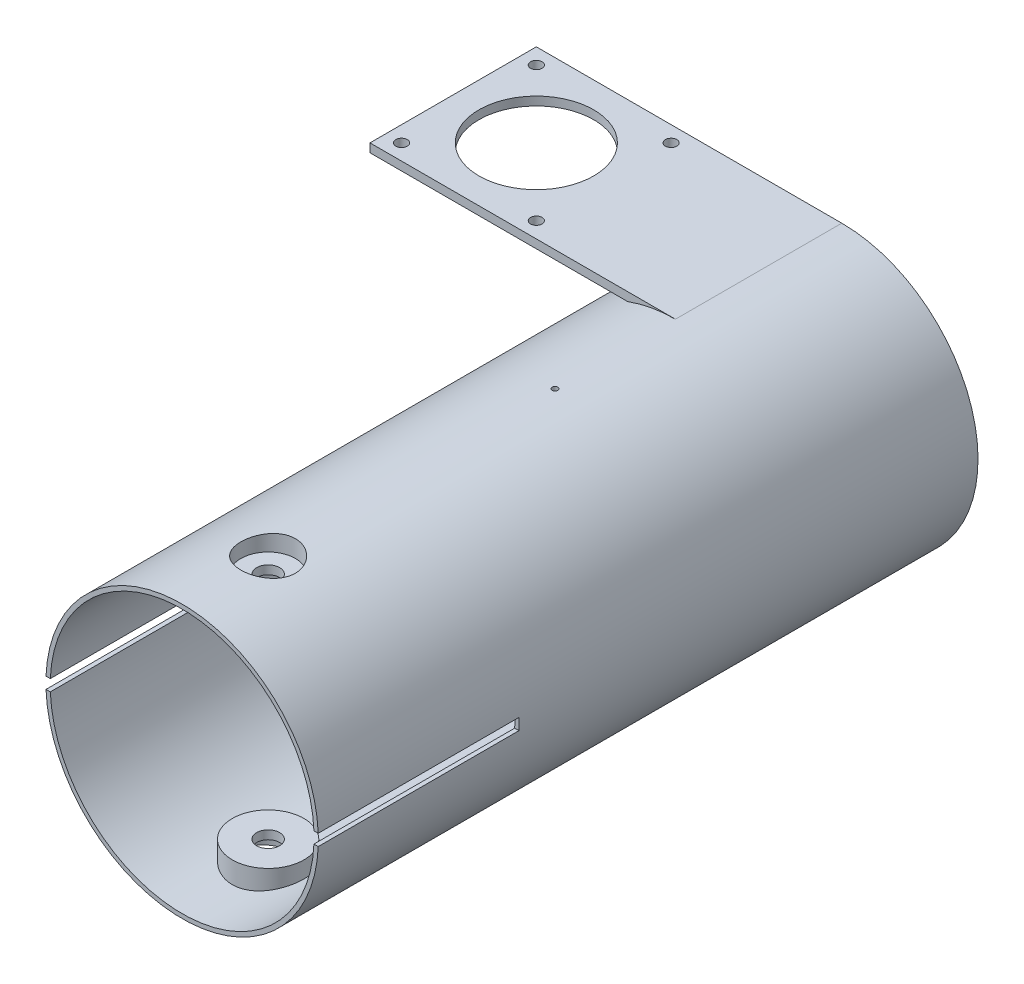
from build123d import *

# Parameters (mm, degrees)
SKETCH1_R               = 47.5
SKETCH1_R_2             = 46
BOSS_EXTRUDE1_DEPTH     = 250
CUT_EXTRUDE1_DEPTH      = 250
CUT_EXTRUDE1_DEPTH_BACK = 250
SKETCH2_R               = 1
CUT_EXTRUDE2_DEPTH      = 75
CUT_EXTRUDE2_DEPTH_BACK = 79
SKETCH3_W               = 95
SKETCH3_H               = 20
CUT_EXTRUDE3_DEPTH      = 64
CUT_EXTRUDE3_DEPTH_BACK = 73
SKETCH4_R               = 9.5
BOSS_EXTRUDE2_REACH     = 271.587
SKETCH5_R               = 12.5
SKETCH5_R_2             = 9.5
BOSS_EXTRUDE7_START     = 3
SKETCH10_R              = 12.5
SKETCH10_R_2            = 4
BOSS_EXTRUDE7_DEPTH     = 3
BOSS_EXTRUDE8_REACH     = 271.587
SKETCH12_R              = 12.5
SKETCH12_R_2            = 9.5
SKETCH13_R              = 12.5
SKETCH13_R_2            = 4
BOSS_EXTRUDE9_DEPTH     = 3
BOSS_EXTRUDE11_DEPTH    = 58
SKETCH18_R              = 2
SKETCH18_R_2            = 20
CUT_EXTRUDE5_DEPTH      = 58
CUT_EXTRUDE6_DEPTH      = 98
CUT_EXTRUDE6_DEPTH_BACK = 82


with BuildPart() as part:
    # Sketch1 → Boss-Extrude1 (new body)
    with BuildSketch(Plane.XY):
        Circle(SKETCH1_R)
        Circle(SKETCH1_R_2, mode=Mode.SUBTRACT)
    extrude(amount=BOSS_EXTRUDE1_DEPTH)

    # Sketch2 → Cut-Extrude1 (cut, two sides: drawn at the far end of the back side and taken through both)
    with BuildSketch(Plane(origin=(0, 0, 0), x_dir=(1, 0, 0), z_dir=(0, 1, 0)).offset(-CUT_EXTRUDE1_DEPTH_BACK)):
        with Locations((0, -120)):
            Circle(SKETCH2_R)
    extrude(amount=CUT_EXTRUDE1_DEPTH + CUT_EXTRUDE1_DEPTH_BACK, mode=Mode.SUBTRACT)

    # Sketch3 → Cut-Extrude2 (cut, two sides: drawn at the far end of the back side and taken through both)
    with BuildSketch(Plane(origin=(0, 0, 0), x_dir=(1, 0, 0), z_dir=(0, 1, 0)).offset(-CUT_EXTRUDE2_DEPTH_BACK)):
        with Locations((0, -10)):
            Rectangle(SKETCH3_W, SKETCH3_H)
    extrude(amount=CUT_EXTRUDE2_DEPTH + CUT_EXTRUDE2_DEPTH_BACK, mode=Mode.SUBTRACT)

    # Sketch4 → Cut-Extrude3 (cut, two sides: drawn at the far end of the back side and taken through both)
    with BuildSketch(Plane(origin=(0, 0, 0), x_dir=(1, 0, 0), z_dir=(0, 1, 0)).offset(-CUT_EXTRUDE3_DEPTH_BACK)):
        with Locations((0, -220)):
            Circle(SKETCH4_R)
    extrude(amount=CUT_EXTRUDE3_DEPTH + CUT_EXTRUDE3_DEPTH_BACK, mode=Mode.SUBTRACT)

    # Sketch5 → Boss-Extrude2 (add, up to next)
    with BuildSketch(Plane(origin=(0, 41.5, 0), x_dir=(1, 0, 0), z_dir=(0, 1, 0)), mode=Mode.PRIVATE) as boss_extrude2_sk1:
        with Locations((0, -220)):
            Circle(SKETCH5_R)
        with Locations((0, -220)):
            Circle(SKETCH5_R_2, mode=Mode.SUBTRACT)
    boss_extrude2_tool1 = extrude(boss_extrude2_sk1.sketch, amount=BOSS_EXTRUDE2_REACH, mode=Mode.PRIVATE) - part.part
    add(boss_extrude2_tool1.solids().sort_by_distance((-12.146447, 41.5, 220))[0])

    # Sketch10 → Boss-Extrude7 (add)
    with BuildSketch(Plane.XZ.offset(-41.5).offset(BOSS_EXTRUDE7_START)):
        with Locations((0, 220)):
            Circle(SKETCH10_R)
        with Locations((0, 220)):
            Circle(SKETCH10_R_2, mode=Mode.SUBTRACT)
    extrude(amount=-BOSS_EXTRUDE7_DEPTH)

    # Sketch12 → Boss-Extrude8 (add, up to next)
    with BuildSketch(Plane(origin=(0, -41.5, 0), x_dir=(1, 0, 0), z_dir=(0, 1, 0)), mode=Mode.PRIVATE) as boss_extrude8_sk1:
        with Locations((0, -220)):
            Circle(SKETCH12_R)
        with Locations((0, -220)):
            Circle(SKETCH12_R_2, mode=Mode.SUBTRACT)
    boss_extrude8_tool1 = extrude(boss_extrude8_sk1.sketch, amount=-BOSS_EXTRUDE8_REACH, mode=Mode.PRIVATE) - part.part
    add(boss_extrude8_tool1.solids().sort_by_distance((-12.146447, -41.5, 220))[0])

    # Sketch13 → Boss-Extrude9 (add)
    with BuildSketch(Plane(origin=(0, -41.5, 0), x_dir=(1, 0, 0), z_dir=(0, 1, 0))):
        with Locations((0, -220)):
            Circle(SKETCH13_R)
        with Locations((0, -220)):
            Circle(SKETCH13_R_2, mode=Mode.SUBTRACT)
    extrude(amount=BOSS_EXTRUDE9_DEPTH)

    # Sketch17 → Boss-Extrude11 (add)
    with BuildSketch(Plane.XY.offset(20)):
        with BuildLine():
            Line((0, 47.5), (-106.5, 47.5))
            Line((-106.5, 47.5), (-106.5, 44.5))
            Line((-106.5, 44.5), (-16.613247726, 44.5))
            ThreePointArc((-16.613247726, 44.5), (-8.440971508, 46.74398357), (0, 47.5))
        make_face()
    extrude(amount=BOSS_EXTRUDE11_DEPTH)

    # Sketch18 → Cut-Extrude5 (cut)
    with BuildSketch(Plane(origin=(0, 47.5, 0), x_dir=(1, 0, 0), z_dir=(0, 1, 0))):
        with Locations((-101, -72.5)):
            Circle(SKETCH18_R)
        with Locations((-101, -25.5)):
            Circle(SKETCH18_R)
        with Locations((-54, -25.5)):
            Circle(SKETCH18_R)
        with Locations((-54, -72.5)):
            Circle(SKETCH18_R)
        with Locations((-77.5, -49)):
            Circle(SKETCH18_R_2)
    extrude(amount=-CUT_EXTRUDE5_DEPTH, mode=Mode.SUBTRACT)

    # Sketch19 → Cut-Extrude6 (cut, two sides: drawn at the far end of the back side and taken through both)
    with BuildSketch(Plane(origin=(0, 0, 0), x_dir=(0, 0, -1), z_dir=(1, 0, 0)).offset(-CUT_EXTRUDE6_DEPTH_BACK)):
        Polygon((-180, 0), (-180, -2), (-250, -2), (-250, 0), (-250, 2), (-180, 2), align=None)
    extrude(amount=CUT_EXTRUDE6_DEPTH + CUT_EXTRUDE6_DEPTH_BACK, mode=Mode.SUBTRACT)


solid = part.part
